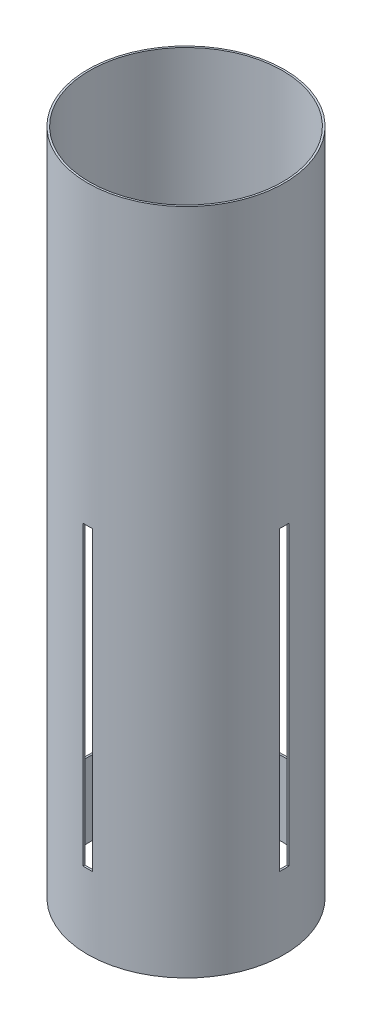
from build123d import *

# Parameters (mm, degrees)
SKETCH1_R           = 67.31
SKETCH1_R_2         = 66.04
BOSS_EXTRUDE1_DEPTH = 457.2
SKETCH3_W           = 6.35
SKETCH3_H           = 203.2
CUT_EXTRUDE1_DEPTH  = 68.31
CIRPATTERN1_COUNT   = 4


with BuildPart() as part:
    # Sketch1 → Boss-Extrude1 (new body)
    with BuildSketch(Plane(origin=(0, 0, 0), x_dir=(1, 0, 0), z_dir=(0, 1, 0))):
        Circle(SKETCH1_R)
        Circle(SKETCH1_R_2, mode=Mode.SUBTRACT)
    extrude(amount=BOSS_EXTRUDE1_DEPTH)

    # Sketch3 → Cut-Extrude1 (cut, symmetric)
    with BuildSketch(Plane.XY):
        with Locations((0, 152.4)):
            Rectangle(SKETCH3_W, SKETCH3_H)
    cut_extrude1 = extrude(amount=CUT_EXTRUDE1_DEPTH, both=True, mode=Mode.SUBTRACT)

    # CirPattern1: Cut-Extrude1 ×4 about axis
    cirpattern1_axis = Axis((0, 0, 0), (0, 1, 0))
    for i in range(1, CIRPATTERN1_COUNT):
        add(cut_extrude1.rotate(cirpattern1_axis, i * 360 / CIRPATTERN1_COUNT), mode=Mode.SUBTRACT)


solid = part.part
